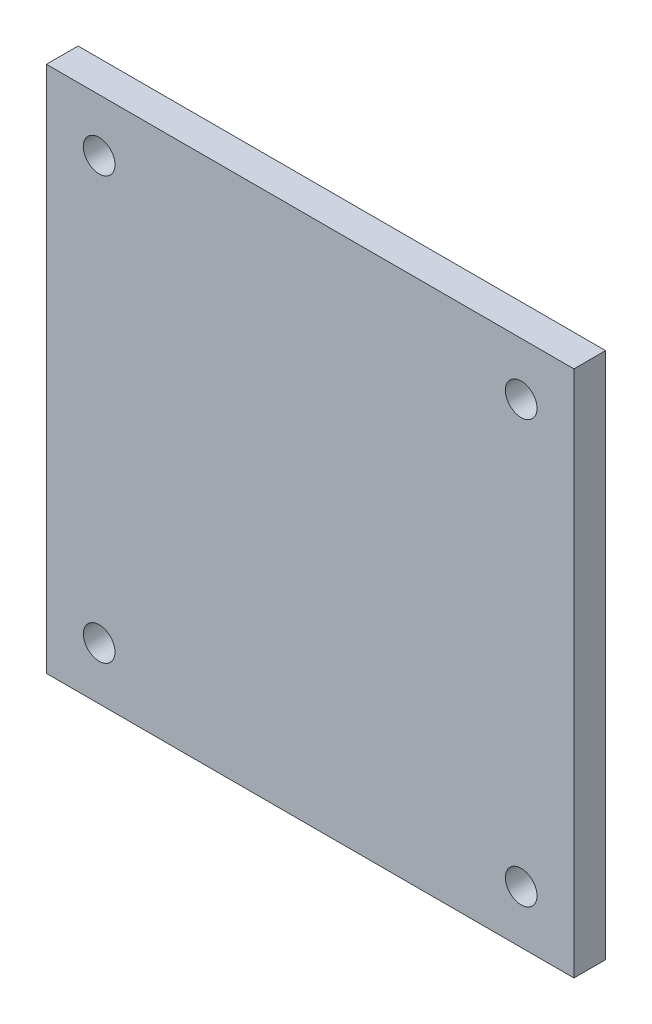
from build123d import *

# Parameters (mm, degrees)
SKETCH1_W           = 50
SKETCH1_H           = 50
SKETCH1_R           = 1.5
BOSS_EXTRUDE1_DEPTH = 3


with BuildPart() as part:
    # Sketch1 → Boss-Extrude1 (new body)
    with BuildSketch(Plane.XY):
        with Locations((25, 25)):
            Rectangle(SKETCH1_W, SKETCH1_H)
        with Locations((5, 45)):
            Circle(SKETCH1_R, mode=Mode.SUBTRACT)
        with Locations((45, 45)):
            Circle(SKETCH1_R, mode=Mode.SUBTRACT)
        with Locations((45, 5)):
            Circle(SKETCH1_R, mode=Mode.SUBTRACT)
        with Locations((5, 5)):
            Circle(SKETCH1_R, mode=Mode.SUBTRACT)
    extrude(amount=BOSS_EXTRUDE1_DEPTH)


solid = part.part
